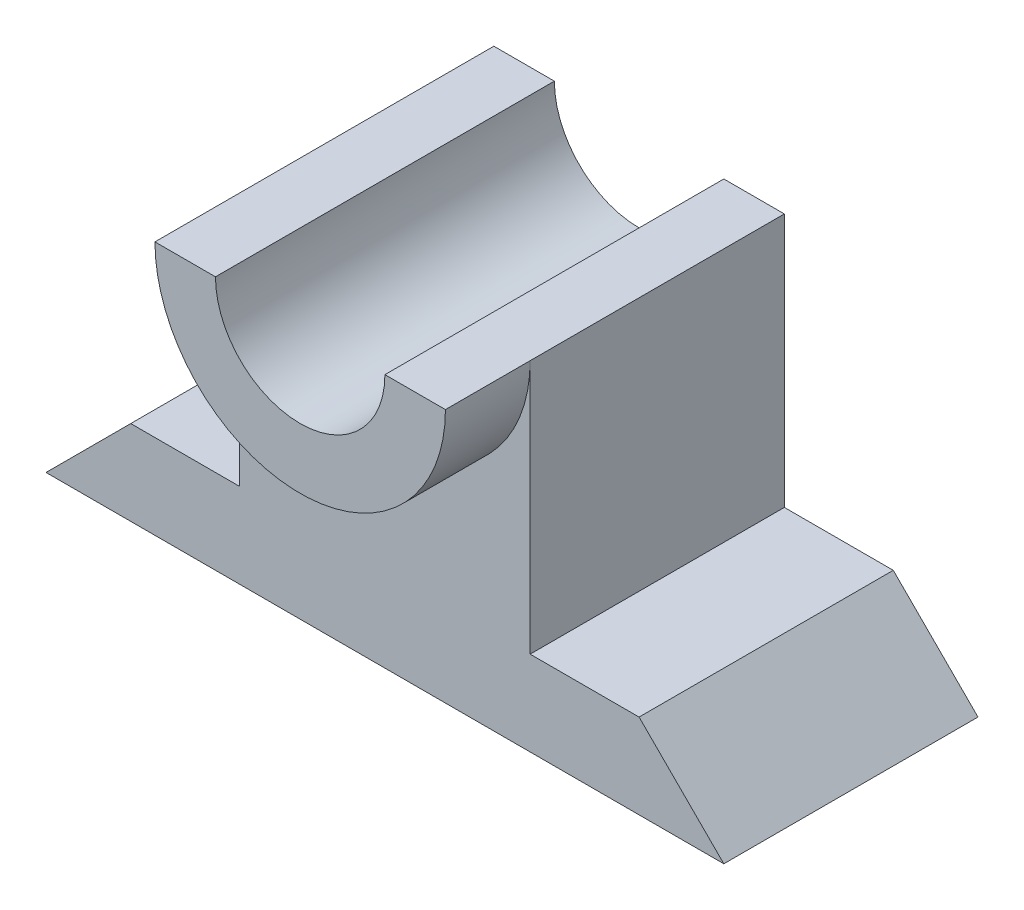
from build123d import *

# Parameters (mm, degrees)
BOSS_EXTRUDE2_DEPTH = 30
BOSS_EXTRUDE3_DEPTH = 10


with BuildPart() as part:
    # Sketch1 → Boss-Extrude2 (new body)
    with BuildSketch(Plane.XY):
        with BuildLine():
            ThreePointArc((-17.142857143, 40), (0, 22.857142857), (17.142857143, 40))
            Line((17.142857143, 40), (17.142857143, 10))
            Line((17.142857143, 10), (30, 10))
            Line((30, 10), (40, 0))
            Line((40, 0), (-40, 0))
            Line((-40, 0), (-30, 10))
            Line((-30, 10), (-17.142857143, 10))
            Line((-17.142857143, 10), (-17.142857143, 40))
        make_face()
        with BuildLine():
            Line((-10, 40), (-17.142857143, 40))
            ThreePointArc((-17.142857143, 40), (0, 22.857142857), (17.142857143, 40))
            Line((17.142857143, 40), (10, 40))
            ThreePointArc((10, 40), (0, 30), (-10, 40))
        make_face()
    extrude(amount=-BOSS_EXTRUDE2_DEPTH)

    # Sketch1_5 → Boss-Extrude3 (add)
    with BuildSketch(Plane.XY):
        with BuildLine():
            Line((-10, 40), (-17.142857143, 40))
            ThreePointArc((-17.142857143, 40), (0, 22.857142857), (17.142857143, 40))
            Line((17.142857143, 40), (10, 40))
            ThreePointArc((10, 40), (0, 30), (-10, 40))
        make_face()
    extrude(amount=BOSS_EXTRUDE3_DEPTH)


solid = part.part
